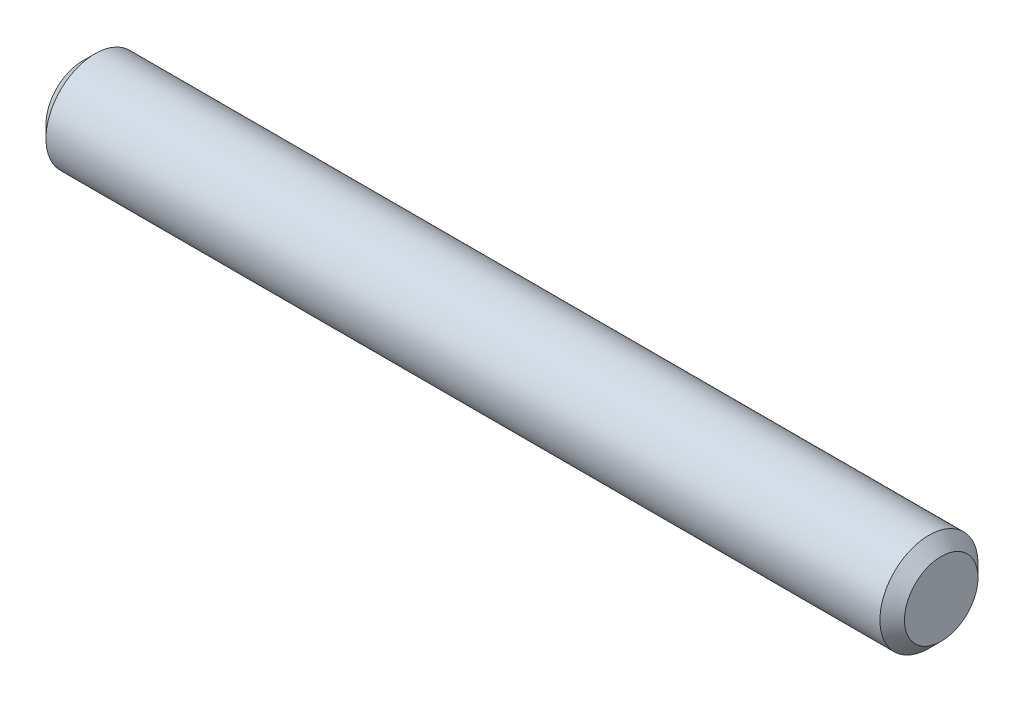
from build123d import *

# Parameters (mm, degrees)
SKIZZE1_R                       = 2
AUFSATZ_LINEAR_AUSTRAGEN1_DEPTH = 17.5
FASE1_SIZE                      = 0.5


with BuildPart() as part:
    # Skizze1 → Aufsatz-Linear austragen1 (new body, symmetric)
    with BuildSketch(Plane(origin=(0, 0, 0), x_dir=(0, 0, -1), z_dir=(1, 0, 0))):
        Circle(SKIZZE1_R)
    extrude(amount=AUFSATZ_LINEAR_AUSTRAGEN1_DEPTH, both=True)

    # Fase1
    fase1_edges = [part.edges().sort_by_distance(p)[0] for p in [
        (-17.5, 0, 2),
        (17.5, 0, 2),
    ]]
    chamfer(fase1_edges, length=FASE1_SIZE)


solid = part.part
